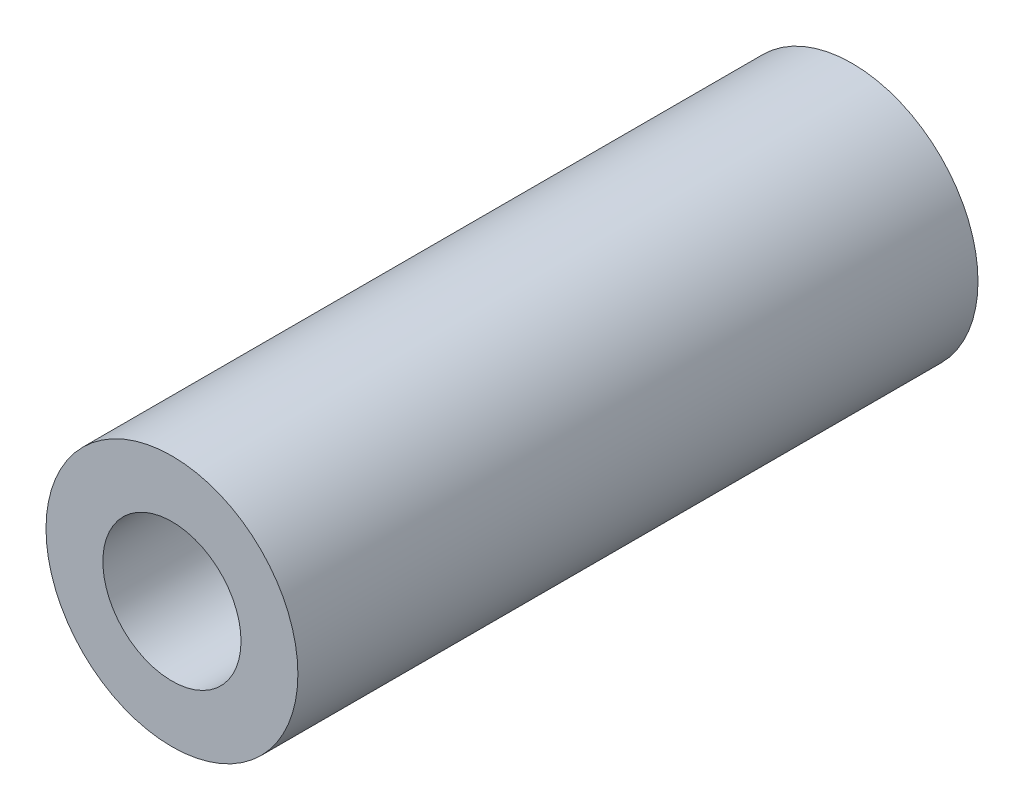
from build123d import *

# Parameters (mm, degrees)
ESBO_O1_R                = 3.1
ESBO_O1_R_2              = 1.55
RESSALTO_EXTRUS_O1_DEPTH = 16.74
M3_CLEARANCE_HOLE1_D     = 3.4


with BuildPart() as part:
    # Esboço1 → Ressalto-extrusão1 (new body)
    with BuildSketch(Plane.XY):
        with Locations((16.016666667, 16.016666667)):
            Circle(ESBO_O1_R)
        with Locations((16.016666667, 16.016666667)):
            Circle(ESBO_O1_R_2, mode=Mode.SUBTRACT)
    extrude(amount=RESSALTO_EXTRUS_O1_DEPTH)

    # M3 Clearance Hole1 (through all)
    with Locations(Plane(origin=(16.016666667, 16.016666667, 16.74), x_dir=(1, 0, 0), z_dir=(0, 0, 1))):
        with Locations((0, 0)):
            Hole(M3_CLEARANCE_HOLE1_D / 2)


solid = part.part
